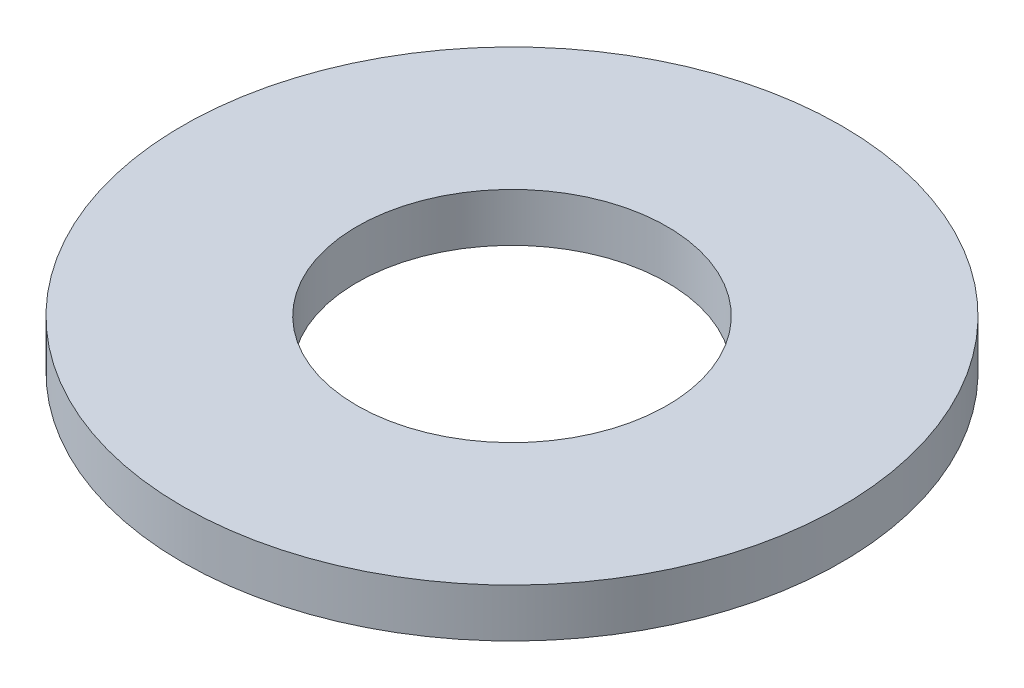
from build123d import *

# Parameters (mm, degrees)
SKETCH1_R      = 3.4
SKETCH1_R_2    = 1.6
EXTRUDE1_DEPTH = 0.5


with BuildPart() as part:
    # Sketch1 → Extrude1 (new body)
    with BuildSketch(Plane(origin=(0, 0, 0), x_dir=(1, 0, 0), z_dir=(0, 1, 0))):
        with Locations(Location((0, 0, 0), (0, 0, 270))):  # turned: the seam where the file's is
            Circle(SKETCH1_R)
        with Locations(Location((0, 0, 0), (0, 0, 270))):  # turned: the seam where the file's is
            Circle(SKETCH1_R_2, mode=Mode.SUBTRACT)
    extrude(amount=EXTRUDE1_DEPTH)


solid = part.part
